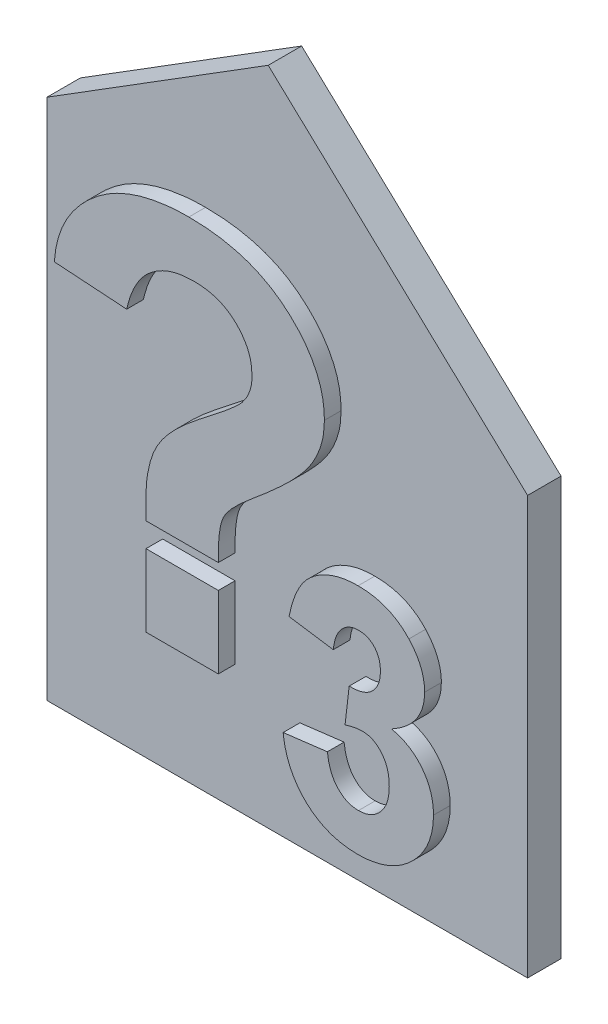
from build123d import *

# Parameters (mm, degrees)
P_IDAT_VYSUNUT_M5_DEPTH = 1.6
SKICA2_W                = 3.461538462
SKICA2_H                = 3.461538462
P_IDAT_VYSUNUT_M7_DEPTH = 0.8


with BuildPart() as part:
    # Skica1 → Přidat vysunutím5 (new body)
    with BuildSketch(Plane.XY):
        Polygon((0, 0), (0, 20), (-12.412784718, 31.615626352), (-23, 25), (-23, 0), align=None)
    extrude(amount=P_IDAT_VYSUNUT_M5_DEPTH)

    # Skica2 → Přidat vysunutím7 (add)
    with BuildSketch(Plane.XY.offset(1.6)):
        with BuildLine():
            Line((-14, 10.615384615), (-17.461538462, 10.615384615))
            add(Edge.make_bspline(
                [(-17.461538462, 10.615384615), (-17.462761041, 10.717547725), (-17.464947341, 10.900242799), (-17.467563382, 11.140642952), (-17.472945146, 11.314884938), (-17.472519469, 11.408652071), (-17.472355769, 11.444711538)],
                knots=[0, 0, 0, 0, 0.000306512, 0.000548125, 0.00072124, 0.000829413, 0.000829413, 0.000829413, 0.000829413], degree=3))
            add(Edge.make_bspline(
                [(-17.472355769, 11.444711538), (-17.467143753, 11.689118273), (-17.457157848, 12.157386642), (-17.353713641, 12.826229074), (-17.192761244, 13.429486458), (-16.991015257, 13.88672109), (-16.786027719, 14.226204424), (-16.601328573, 14.487266983), (-16.379690706, 14.75153528), (-16.13046496, 15.027939199), (-15.844619722, 15.309081719), (-15.522033919, 15.5945171), (-15.174392431, 15.89716344), (-14.795111585, 16.188373916), (-14.42261968, 16.475030351), (-14.081466076, 16.746058228), (-13.777391698, 16.985911005), (-13.517107268, 17.203032521), (-13.297866611, 17.393855557), (-13.116383208, 17.556014178), (-12.974939992, 17.690286431), (-12.899782361, 17.776008793), (-12.867788462, 17.8125)],
                knots=[0, 0, 0, 0, 0.00073269, 0.00140379, 0.002024904, 0.002601162, 0.002895512, 0.003213659, 0.003559456, 0.003929588, 0.004329893, 0.004761397, 0.005221722, 0.005712226, 0.006195453, 0.006631885, 0.007019317, 0.00735726, 0.007648637, 0.00789119, 0.008087531, 0.008233063, 0.008233063, 0.008233063, 0.008233063], degree=3))
            add(Edge.make_bspline(
                [(-12.867788462, 17.8125), (-12.792950123, 17.913483344), (-12.646192633, 18.111511016), (-12.496451852, 18.444269694), (-12.399486981, 18.790168903), (-12.38960701, 19.026987526), (-12.384615385, 19.146634615)],
                knots=[0, 0, 0, 0, 0.000376056, 0.000737443, 0.001088168, 0.001446303, 0.001446303, 0.001446303, 0.001446303], degree=3))
            add(Edge.make_bspline(
                [(-12.384615385, 19.146634615), (-12.393277033, 19.315893594), (-12.410299809, 19.648538996), (-12.556125659, 20.12787988), (-12.801211538, 20.565085311), (-13.077289764, 20.889680981), (-13.335716537, 21.122150559), (-13.550955679, 21.273722073), (-13.778948837, 21.406151132), (-14.026872382, 21.509518063), (-14.290703412, 21.593988444), (-14.57274717, 21.649089312), (-14.869133464, 21.687528601), (-15.071983956, 21.690693117), (-15.175480769, 21.692307692)],
                knots=[0, 0, 0, 0, 0.000506979, 0.000996369, 0.001487032, 0.002001344, 0.00226695, 0.002528088, 0.002789724, 0.003056283, 0.00333226, 0.003619366, 0.003917229, 0.004227514, 0.004227514, 0.004227514, 0.004227514], degree=3))
            add(Edge.make_bspline(
                [(-15.175480769, 21.692307692), (-15.373220624, 21.684057503), (-15.75735434, 21.668030508), (-16.309879055, 21.542140198), (-16.808699102, 21.320051468), (-17.182023211, 21.070543208), (-17.448676621, 20.828429744), (-17.632329594, 20.622963667), (-17.798137837, 20.393471006), (-17.950538021, 20.144716578), (-18.083777541, 19.871221399), (-18.202676962, 19.576286759), (-18.303293583, 19.257595852), (-18.357066238, 19.036400914), (-18.384615385, 18.923076923)],
                knots=[0, 0, 0, 0, 0.000592927, 0.001151833, 0.001687821, 0.002222861, 0.002490879, 0.002766668, 0.003047941, 0.003339206, 0.003640757, 0.003959475, 0.004292457, 0.004642273, 0.004642273, 0.004642273, 0.004642273], degree=3))
            Line((-18.384615385, 18.923076923), (-21.846153846, 19.153846154))
            add(Edge.make_bspline(
                [(-21.846153846, 19.153846154), (-21.830715159, 19.327456441), (-21.800228098, 19.670287893), (-21.688730553, 20.171687025), (-21.529907072, 20.653987672), (-21.319971868, 21.117188821), (-21.058909052, 21.559725335), (-20.745089466, 21.978549214), (-20.387457296, 22.382338979), (-19.977292086, 22.756779188), (-19.528144679, 23.103636722), (-19.041124231, 23.407705146), (-18.516471094, 23.660288393), (-17.960437015, 23.869834332), (-17.370106016, 24.032199949), (-16.746207434, 24.145322755), (-16.089602325, 24.221052927), (-15.63964403, 24.227484635), (-15.409855769, 24.230769231)],
                knots=[0, 0, 0, 0, 0.000522426, 0.001031644, 0.001536774, 0.002043484, 0.002554283, 0.003074964, 0.003611267, 0.004170115, 0.004738421, 0.005311738, 0.005889067, 0.006482432, 0.007092159, 0.007722994, 0.008383194, 0.009072236, 0.009072236, 0.009072236, 0.009072236], degree=3))
            add(Edge.make_bspline(
                [(-15.409855769, 24.230769231), (-15.168098885, 24.225825499), (-14.696692228, 24.216185617), (-14.007942642, 24.143978532), (-13.357138729, 24.02080662), (-12.74254362, 23.854498424), (-12.168892406, 23.63155874), (-11.631323067, 23.364903848), (-11.132317549, 23.046670274), (-10.676590221, 22.682907141), (-10.267281072, 22.288168754), (-9.90914527, 21.872658825), (-9.602902134, 21.443261001), (-9.356363086, 20.994584265), (-9.159207923, 20.53290037), (-9.021130659, 20.052260004), (-8.941257551, 19.555565687), (-8.929172693, 19.219031398), (-8.923076923, 19.049278846)],
                knots=[0, 0, 0, 0, 0.000725199, 0.00141408, 0.002074596, 0.002710572, 0.003321268, 0.003917912, 0.004508069, 0.00509316, 0.005664376, 0.006211527, 0.006736745, 0.00724352, 0.007744449, 0.00823974, 0.00874006, 0.009249291, 0.009249291, 0.009249291, 0.009249291], degree=3))
            add(Edge.make_bspline(
                [(-8.923076923, 19.049278846), (-8.930375302, 18.859912911), (-8.944941797, 18.48196628), (-9.073631501, 17.924037167), (-9.281887296, 17.38221444), (-9.523098679, 16.94246279), (-9.773907688, 16.590678021), (-10.004260679, 16.296683303), (-10.288897554, 15.986282359), (-10.612214988, 15.644702447), (-10.988644644, 15.287593712), (-11.408234549, 14.902800918), (-11.876979116, 14.497871601), (-12.206405416, 14.220763964), (-12.377403846, 14.076923077)],
                knots=[0, 0, 0, 0, 0.000567494, 0.001132634, 0.001707864, 0.002304998, 0.002631115, 0.003003349, 0.003424669, 0.003893918, 0.004414149, 0.004980748, 0.005601831, 0.006272194, 0.006272194, 0.006272194, 0.006272194], degree=3))
            add(Edge.make_bspline(
                [(-12.377403846, 14.076923077), (-12.46528451, 14.002580816), (-12.633785822, 13.860037872), (-12.874694056, 13.651537649), (-13.084667117, 13.448946977), (-13.275872464, 13.263452835), (-13.432261399, 13.082003863), (-13.569152359, 12.916050643), (-13.676465154, 12.759178553), (-13.76165463, 12.607756436), (-13.824711451, 12.447258153), (-13.879123392, 12.266645373), (-13.91972505, 12.057361457), (-13.956971663, 11.821861455), (-13.98104236, 11.559310964), (-13.994233691, 11.269368327), (-14.001656529, 10.951961072), (-14.000567907, 10.730772893), (-14, 10.615384615)],
                knots=[0, 0, 0, 0, 0.000345345, 0.000662161, 0.000955472, 0.001220637, 0.001460793, 0.001673656, 0.001865678, 0.002030284, 0.002193662, 0.002381889, 0.002595452, 0.002832585, 0.003097013, 0.003385835, 0.003703225, 0.004049379, 0.004049379, 0.004049379, 0.004049379], degree=3))
        make_face()
        with Locations((-15.730769231, 7.730769231)):
            Rectangle(SKICA2_W, SKICA2_H)
        with BuildLine():
            Line((-10.897435897, 5.124599359), (-8.782051282, 5.384615385))
            add(Edge.make_bspline(
                [(-8.782051282, 5.384615385), (-8.763782741, 5.254544873), (-8.729106476, 5.007652717), (-8.620984497, 4.665922644), (-8.479836659, 4.368543902), (-8.292964005, 4.124885808), (-8.076907759, 3.931099662), (-7.835955097, 3.792826196), (-7.572285552, 3.705628317), (-7.388635474, 3.696816322), (-7.294671474, 3.692307692)],
                knots=[0, 0, 0, 0, 0.000393414, 0.000746756, 0.001070973, 0.001375953, 0.001661605, 0.001936012, 0.002204309, 0.002485403, 0.002485403, 0.002485403, 0.002485403], degree=3))
            add(Edge.make_bspline(
                [(-7.294671474, 3.692307692), (-7.243909755, 3.693397773), (-7.14335872, 3.695557054), (-6.995546127, 3.718212143), (-6.853521416, 3.755451715), (-6.718685867, 3.809036685), (-6.590395801, 3.875616739), (-6.466961848, 3.954904527), (-6.353569229, 4.053931677), (-6.242861407, 4.162277869), (-6.144618031, 4.285612089), (-6.058077315, 4.419424543), (-5.982111751, 4.562388011), (-5.923230652, 4.718188627), (-5.877139964, 4.88345154), (-5.844189532, 5.058894123), (-5.824135927, 5.243855052), (-5.82173707, 5.370608328), (-5.820512821, 5.435296474)],
                knots=[0, 0, 0, 0, 0.000152187, 0.000301458, 0.000447374, 0.000591819, 0.000735708, 0.000880555, 0.001030654, 0.001186466, 0.001344768, 0.001502455, 0.001664095, 0.001829418, 0.002001039, 0.002178227, 0.002364383, 0.002558406, 0.002558406, 0.002558406, 0.002558406], degree=3))
            add(Edge.make_bspline(
                [(-5.820512821, 5.435296474), (-5.825098497, 5.555353817), (-5.833846176, 5.784376293), (-5.901442274, 6.109297175), (-6.018665984, 6.394915815), (-6.182902147, 6.636108354), (-6.378061443, 6.830129643), (-6.59668007, 6.975971606), (-6.840824252, 7.059756717), (-7.010549264, 7.071158751), (-7.096354167, 7.076923077)],
                knots=[0, 0, 0, 0, 0.000359992, 0.000686723, 0.000989962, 0.001280268, 0.001556061, 0.001810928, 0.002062487, 0.002319696, 0.002319696, 0.002319696, 0.002319696], degree=3))
            add(Edge.make_bspline(
                [(-7.096354167, 7.076923077), (-7.157441924, 7.075359952), (-7.286941523, 7.072046291), (-7.488371138, 7.03761698), (-7.708031006, 6.990102976), (-7.857602681, 6.944397654), (-7.935897436, 6.920472756)],
                knots=[0, 0, 0, 0, 0.000183105, 0.000388163, 0.000611634, 0.000857107, 0.000857107, 0.000857107, 0.000857107], degree=3))
            Line((-7.935897436, 6.920472756), (-7.737580128, 8.628205128))
            add(Edge.make_bspline(
                [(-7.737580128, 8.628205128), (-7.678794998, 8.627196719), (-7.564722734, 8.625239907), (-7.398143008, 8.639050898), (-7.242219249, 8.664266682), (-7.097315277, 8.705179154), (-6.963296169, 8.754814337), (-6.838989821, 8.817177247), (-6.727437316, 8.89478467), (-6.591614909, 9.011932664), (-6.452656308, 9.187471917), (-6.327028941, 9.428175666), (-6.257031889, 9.702628831), (-6.248175648, 9.894853823), (-6.243589744, 9.994391026)],
                knots=[0, 0, 0, 0, 0.000176282, 0.000342074, 0.000500744, 0.000649363, 0.000793016, 0.000929011, 0.001065309, 0.001199634, 0.001465996, 0.001731098, 0.002009022, 0.002307484, 0.002307484, 0.002307484, 0.002307484], degree=3))
            add(Edge.make_bspline(
                [(-6.243589744, 9.994391026), (-6.246681562, 10.079149815), (-6.252609899, 10.241668666), (-6.305791103, 10.472925469), (-6.396560361, 10.677096608), (-6.523525824, 10.850638064), (-6.679269851, 10.991559039), (-6.861310156, 11.095689373), (-7.069819381, 11.15641123), (-7.21640967, 11.163163339), (-7.292467949, 11.166666667)],
                knots=[0, 0, 0, 0, 0.000254018, 0.000487061, 0.000706994, 0.000919871, 0.001127389, 0.001332649, 0.001543923, 0.001771751, 0.001771751, 0.001771751, 0.001771751], degree=3))
            add(Edge.make_bspline(
                [(-7.292467949, 11.166666667), (-7.368717883, 11.162897402), (-7.518598833, 11.155488334), (-7.733067597, 11.082200901), (-7.930926531, 10.968807682), (-8.105522826, 10.806418048), (-8.25684922, 10.604447031), (-8.374116249, 10.358127954), (-8.456701297, 10.071319888), (-8.48508422, 9.864892089), (-8.5, 9.756410256)],
                knots=[0, 0, 0, 0, 0.00022803, 0.000448229, 0.00067235, 0.00090788, 0.001158201, 0.001425273, 0.001721604, 0.002049811, 0.002049811, 0.002049811, 0.002049811], degree=3))
            Line((-8.5, 9.756410256), (-10.615384615, 10.073717949))
            add(Edge.make_bspline(
                [(-10.615384615, 10.073717949), (-10.580504225, 10.235222935), (-10.513735343, 10.544379659), (-10.377316391, 10.977531522), (-10.217249064, 11.359904668), (-10.030234063, 11.695784097), (-9.808710865, 11.991083658), (-9.545695033, 12.247403388), (-9.24512173, 12.472181074), (-8.907564893, 12.660525065), (-8.540542853, 12.811484014), (-8.149942636, 12.92321265), (-7.736760441, 12.987243182), (-7.4542786, 12.995689095), (-7.310096154, 13)],
                knots=[0, 0, 0, 0, 0.000495485, 0.000948469, 0.001360198, 0.001737104, 0.002098925, 0.00246354, 0.002835055, 0.003221804, 0.003619966, 0.004023133, 0.00443794, 0.004870393, 0.004870393, 0.004870393, 0.004870393], degree=3))
            add(Edge.make_bspline(
                [(-7.310096154, 13), (-7.186546439, 12.997188618), (-6.945152537, 12.991695683), (-6.593143017, 12.944430071), (-6.260082091, 12.86764656), (-5.945505471, 12.759030958), (-5.647954883, 12.620738197), (-5.372397663, 12.446742763), (-5.113053095, 12.245905393), (-4.959440318, 12.089604745), (-4.881810897, 12.010616987)],
                knots=[0, 0, 0, 0, 0.000370514, 0.000723917, 0.001063324, 0.00139433, 0.001720608, 0.002045275, 0.002370151, 0.002702065, 0.002702065, 0.002702065, 0.002702065], degree=3))
            add(Edge.make_bspline(
                [(-4.881810897, 12.010616987), (-4.821847087, 11.94330764), (-4.703412341, 11.810364697), (-4.549640774, 11.59722228), (-4.420942247, 11.375748073), (-4.311772616, 11.150563227), (-4.230587318, 10.916445945), (-4.17006303, 10.677071277), (-4.134113742, 10.430318214), (-4.130180277, 10.263335727), (-4.128205128, 10.179487179)],
                knots=[0, 0, 0, 0, 0.000270316, 0.000533902, 0.000786732, 0.00103807, 0.001283384, 0.001528689, 0.00177799, 0.002029433, 0.002029433, 0.002029433, 0.002029433], degree=3))
            add(Edge.make_bspline(
                [(-4.128205128, 10.179487179), (-4.132513609, 10.061548557), (-4.141006417, 9.829069844), (-4.218938283, 9.490882334), (-4.344195961, 9.171188901), (-4.51739147, 8.868768315), (-4.743198183, 8.586426924), (-5.021174512, 8.326705195), (-5.343152337, 8.079692021), (-5.585152838, 7.940164532), (-5.710336538, 7.867988782)],
                knots=[0, 0, 0, 0, 0.000353396, 0.000696609, 0.001035014, 0.001380483, 0.001738038, 0.002115221, 0.002519356, 0.002952437, 0.002952437, 0.002952437, 0.002952437], degree=3))
            add(Edge.make_bspline(
                [(-5.710336538, 7.867988782), (-5.635845874, 7.850034848), (-5.488849654, 7.814605436), (-5.276495909, 7.742376091), (-5.077625697, 7.649725334), (-4.887368327, 7.547923994), (-4.710445247, 7.427208297), (-4.543427064, 7.293447373), (-4.392701216, 7.138915849), (-4.248272098, 6.975652833), (-4.122022592, 6.796478297), (-4.007948011, 6.610027998), (-3.916320995, 6.411752759), (-3.83795226, 6.206750584), (-3.779557969, 5.991707952), (-3.73383123, 5.768233725), (-3.710911473, 5.534936934), (-3.707070828, 5.376574876), (-3.705128205, 5.296474359)],
                knots=[0, 0, 0, 0, 0.000229812, 0.0004535, 0.000671426, 0.000887383, 0.001100066, 0.001313091, 0.001528113, 0.001746806, 0.001966331, 0.002184758, 0.002401612, 0.002620572, 0.00284244, 0.003069318, 0.003304146, 0.003544492, 0.003544492, 0.003544492, 0.003544492], degree=3))
            add(Edge.make_bspline(
                [(-3.705128205, 5.296474359), (-3.7075967, 5.179483374), (-3.712464904, 4.948761423), (-3.765936177, 4.610144329), (-3.847175411, 4.284711057), (-3.959130283, 3.971146872), (-4.108854981, 3.673288249), (-4.28789372, 3.386956498), (-4.501123143, 3.115003796), (-4.744273129, 2.859491047), (-5.009957232, 2.625624762), (-5.29543393, 2.420205117), (-5.596473629, 2.246343282), (-5.914801215, 2.104178859), (-6.247648622, 1.993565262), (-6.597881187, 1.917541236), (-6.962657953, 1.866821477), (-7.212231501, 1.861614042), (-7.338741987, 1.858974359)],
                knots=[0, 0, 0, 0, 0.0003507, 0.000691627, 0.001025649, 0.001356045, 0.001688142, 0.002023788, 0.002367601, 0.002722978, 0.003080554, 0.003427901, 0.003776378, 0.004121601, 0.0044721, 0.004826546, 0.00519553, 0.00557485, 0.00557485, 0.00557485, 0.00557485], degree=3))
            add(Edge.make_bspline(
                [(-7.338741987, 1.858974359), (-7.458628876, 1.860984272), (-7.694114957, 1.864932215), (-8.038846958, 1.911702003), (-8.36902325, 1.980505864), (-8.682716646, 2.08115851), (-8.982659664, 2.205134363), (-9.263190991, 2.364951549), (-9.531531925, 2.546597034), (-9.778915513, 2.759380216), (-10.008928741, 2.991292111), (-10.210967815, 3.246330424), (-10.391011561, 3.516355211), (-10.545866414, 3.803760437), (-10.674234684, 4.109292941), (-10.774187141, 4.43216408), (-10.85390115, 4.771385133), (-10.882724344, 5.00523884), (-10.897435897, 5.124599359)],
                knots=[0, 0, 0, 0, 0.000359418, 0.000705981, 0.001041793, 0.00137003, 0.001692935, 0.002013546, 0.002336871, 0.002663596, 0.002990817, 0.003315335, 0.003638021, 0.003963368, 0.00429322, 0.004630525, 0.004976374, 0.005336925, 0.005336925, 0.005336925, 0.005336925], degree=3))
        make_face()
    extrude(amount=P_IDAT_VYSUNUT_M7_DEPTH)


solid = part.part
